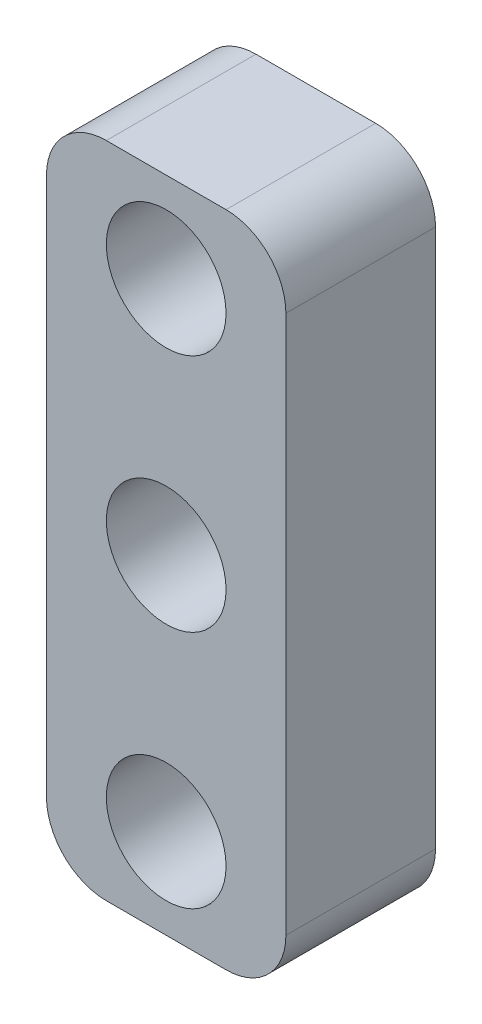
from build123d import *

# Parameters (mm, degrees)
BOSS_EXTRUDE1_DEPTH = 5
SKETCH3_R           = 2
CUT_EXTRUDE2_DEPTH  = 6


with BuildPart() as part:
    # Sketch1 → Boss-Extrude1 (new body)
    with BuildSketch(Plane.XY):
        with BuildLine():
            Line((0, -9), (0, 9))
            ThreePointArc((0, 9), (0.585786438, 10.414213562), (2, 11))
            Line((2, 11), (6, 11))
            ThreePointArc((6, 11), (7.414213562, 10.414213562), (8, 9))
            Line((8, 9), (8, -9))
            ThreePointArc((8, -9), (7.414213562, -10.414213562), (6, -11))
            Line((6, -11), (2, -11))
            ThreePointArc((2, -11), (0.585786438, -10.414213562), (0, -9))
        make_face()
    extrude(amount=BOSS_EXTRUDE1_DEPTH)

    # Sketch3 → Cut-Extrude2 (cut, through all)
    with BuildSketch(Plane.XY.offset(5)):
        with Locations((4, 0)):
            Circle(SKETCH3_R)
        with Locations((4, 8)):
            Circle(SKETCH3_R)
        with Locations((4, -8)):
            Circle(SKETCH3_R)
    extrude(amount=-CUT_EXTRUDE2_DEPTH, mode=Mode.SUBTRACT)


solid = part.part
